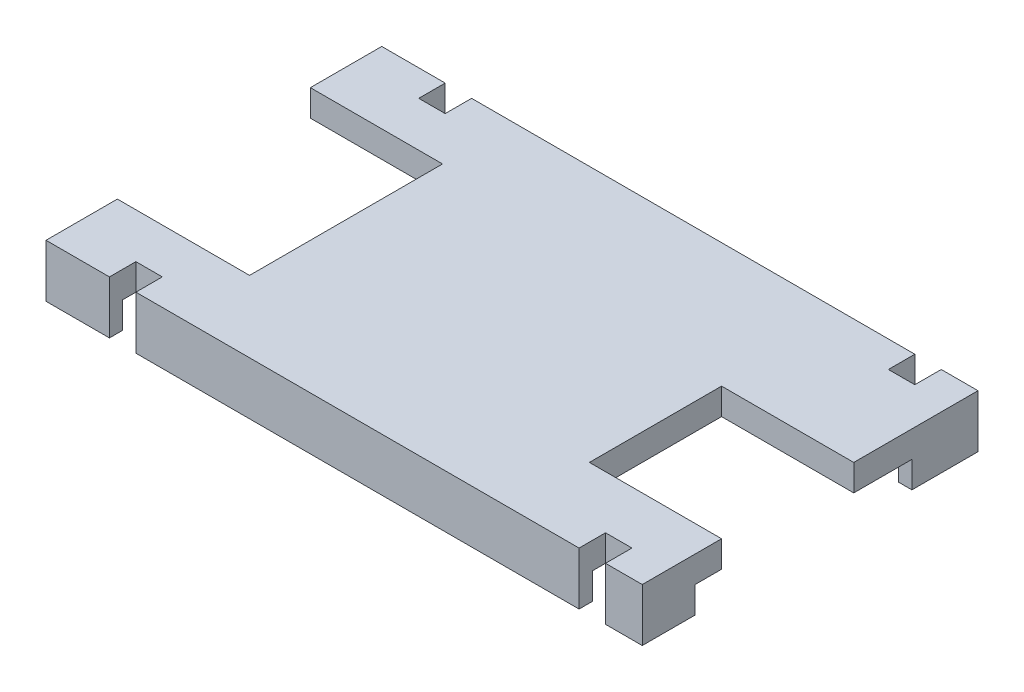
from build123d import *

# Parameters (mm, degrees)
SKETCH1_W           = 22.5552
SKETCH1_H           = 12.7
BOSS_EXTRUDE1_DEPTH = 1
SKETCH2_W           = 5
SKETCH2_H           = 7.3
CUT_EXTRUDE1_DEPTH  = 1
SKETCH3_W           = 5
SKETCH3_H           = 5
CUT_EXTRUDE2_DEPTH  = 1
BOSS_EXTRUDE2_DEPTH = 1
SKETCH7_W           = 1
SKETCH7_H           = 1
CUT_EXTRUDE3_DEPTH  = 3


with BuildPart() as part:
    # Sketch1 → Boss-Extrude1 (new body)
    with BuildSketch(Plane(origin=(0, 0, 0), x_dir=(1, 0, 0), z_dir=(0, 1, 0))):
        with Locations((-28.763088774, 14.606547542)):
            Rectangle(SKETCH1_W, SKETCH1_H)
    extrude(amount=BOSS_EXTRUDE1_DEPTH)

    # Sketch2 → Cut-Extrude1 (cut)
    with BuildSketch(Plane(origin=(0, 1, 0), x_dir=(1, 0, 0), z_dir=(0, 1, 0))):
        with Locations((-37.540688774, 14.606547542)):
            Rectangle(SKETCH2_W, SKETCH2_H)
    extrude(amount=-CUT_EXTRUDE1_DEPTH, mode=Mode.SUBTRACT)

    # Sketch3 → Cut-Extrude2 (cut)
    with BuildSketch(Plane(origin=(0, 1, 0), x_dir=(1, 0, 0), z_dir=(0, 1, 0))):
        with Locations((-19.985488774, 13.756547542)):
            Rectangle(SKETCH3_W, SKETCH3_H)
    extrude(amount=-CUT_EXTRUDE2_DEPTH, mode=Mode.SUBTRACT)

    # Sketch4 → Boss-Extrude2 (add)
    with BuildSketch(Plane.XZ):
        Polygon((-40.040688774, -8.256547542), (-40.040688774, -8.756547542), (-17.985488774, -8.756547542), (-17.985488774, -10.256547542), (-17.485488774, -10.256547542), (-17.485488774, -8.256547542), align=None)
        Polygon((-17.985488774, -20.456547542), (-40.040688774, -20.456547542), (-40.040688774, -20.956547542), (-17.485488774, -20.956547542), (-17.485488774, -18.456547542), (-17.985488774, -18.456547542), align=None)
    extrude(amount=BOSS_EXTRUDE2_DEPTH)

    # Sketch7 → Cut-Extrude3 (cut)
    with BuildSketch(Plane(origin=(0, 1, 0), x_dir=(1, 0, 0), z_dir=(0, 1, 0))):
        with Locations((-37.140688774, 20.456547542)):
            Rectangle(SKETCH7_W, SKETCH7_H)
        with Locations((-37.140688774, 8.756547542)):
            Rectangle(SKETCH7_W, SKETCH7_H)
        with Locations((-19.375488774, 20.456547542)):
            Rectangle(SKETCH7_W, SKETCH7_H)
        with Locations((-19.375488774, 8.756547542)):
            Rectangle(SKETCH7_W, SKETCH7_H)
    extrude(amount=-CUT_EXTRUDE3_DEPTH, mode=Mode.SUBTRACT)


solid = part.part
